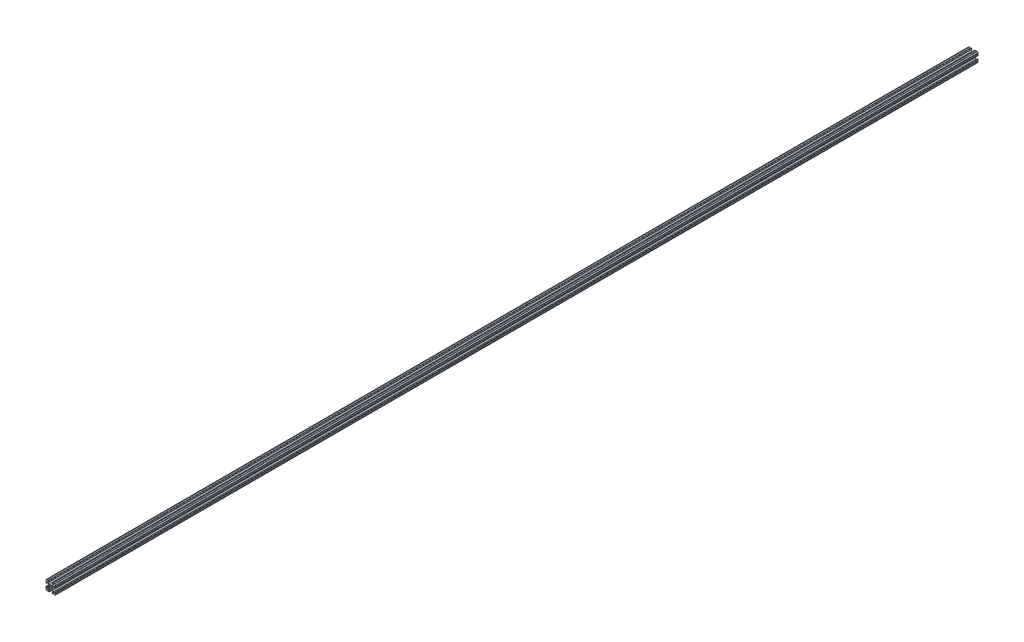
from build123d import *

# Parameters (mm, degrees)
SKETCH1_R           = 2.6035
BOSS_EXTRUDE1_DEPTH = 2438.4


with BuildPart() as part:
    # Sketch1 → Boss-Extrude1 (new body)
    with BuildSketch(Plane.XY):
        with BuildLine():
            Line((-12.7, -6.3330836), (-12.7, -9.5504))
            ThreePointArc((-12.7, -9.5504), (-12.192000006, -10.058323491), (-12.699846982, -10.566399977))
            ThreePointArc((-12.699846982, -10.566399977), (-12.082522516, -12.082522516), (-10.566399977, -12.699846982))
            ThreePointArc((-10.566399977, -12.699846982), (-10.058323491, -12.192000006), (-9.5504, -12.7))
            Line((-9.5504, -12.7), (-6.3330836, -12.7))
            ThreePointArc((-6.3330836, -12.7), (-5.8250836, -12.192), (-5.3170836, -12.7))
            Line((-5.3170836, -12.7), (-4.343399971, -12.7))
            ThreePointArc((-4.343399971, -12.7), (-3.238499971, -11.5951), (-4.343399971, -10.4902))
            Line((-4.343399971, -10.4902), (-6.474794456, -10.4902))
            ThreePointArc((-6.474794456, -10.4902), (-7.413456061, -9.863006367), (-7.193214945, -8.75577951))
            Line((-7.193214945, -8.75577951), (-3.863171405, -5.42573597))
            ThreePointArc((-3.863171405, -5.42573597), (-2.833127272, -4.737482484), (-1.618107374, -4.4958))
            Line((-1.618107374, -4.4958), (1.618107374, -4.4958))
            ThreePointArc((1.618107374, -4.4958), (2.833127272, -4.737482484), (3.863171405, -5.42573597))
            Line((3.863171405, -5.42573597), (7.193214945, -8.75577951))
            ThreePointArc((7.193214945, -8.75577951), (7.413456061, -9.863006367), (6.474794456, -10.4902))
            Line((6.474794456, -10.4902), (4.3434, -10.4902))
            ThreePointArc((4.3434, -10.4902), (3.2385, -11.5951), (4.3434, -12.7))
            Line((4.3434, -12.7), (5.3170836, -12.7))
            ThreePointArc((5.3170836, -12.7), (5.8250836, -12.192), (6.3330836, -12.7))
            Line((6.3330836, -12.7), (9.5504, -12.7))
            ThreePointArc((9.5504, -12.7), (10.058323491, -12.192000006), (10.566399977, -12.699846982))
            ThreePointArc((10.566399977, -12.699846982), (12.082522516, -12.082522516), (12.699846982, -10.566399977))
            ThreePointArc((12.699846982, -10.566399977), (12.192000006, -10.058323491), (12.7, -9.5504))
            Line((12.7, -9.5504), (12.7, -6.3330836))
            ThreePointArc((12.7, -6.3330836), (12.192, -5.8250836), (12.7, -5.3170836))
            Line((12.7, -5.3170836), (12.7, -4.343399971))
            ThreePointArc((12.7, -4.343399971), (11.5951, -3.238499971), (10.4902, -4.343399971))
            Line((10.4902, -4.343399971), (10.4902, -6.474794456))
            ThreePointArc((10.4902, -6.474794456), (9.863006367, -7.413456061), (8.75577951, -7.193214945))
            Line((8.75577951, -7.193214945), (5.42573597, -3.863171405))
            ThreePointArc((5.42573597, -3.863171405), (4.737482484, -2.833127272), (4.4958, -1.618107374))
            Line((4.4958, -1.618107374), (4.4958, 1.618107374))
            ThreePointArc((4.4958, 1.618107374), (4.737482484, 2.833127272), (5.42573597, 3.863171405))
            Line((5.42573597, 3.863171405), (8.75577951, 7.193214945))
            ThreePointArc((8.75577951, 7.193214945), (9.863006367, 7.413456061), (10.4902, 6.474794456))
            Line((10.4902, 6.474794456), (10.4902, 4.3434))
            ThreePointArc((10.4902, 4.3434), (11.5951, 3.2385), (12.7, 4.3434))
            Line((12.7, 4.3434), (12.7, 5.3170836))
            ThreePointArc((12.7, 5.3170836), (12.192, 5.8250836), (12.7, 6.3330836))
            Line((12.7, 6.3330836), (12.7, 9.5504))
            ThreePointArc((12.7, 9.5504), (12.192000006, 10.058323491), (12.699846982, 10.566399977))
            ThreePointArc((12.699846982, 10.566399977), (12.082522516, 12.082522516), (10.566399977, 12.699846982))
            ThreePointArc((10.566399977, 12.699846982), (10.058323491, 12.192000006), (9.5504, 12.7))
            Line((9.5504, 12.7), (6.3330836, 12.7))
            ThreePointArc((6.3330836, 12.7), (5.8250836, 12.192), (5.3170836, 12.7))
            Line((5.3170836, 12.7), (4.343399971, 12.7))
            ThreePointArc((4.343399971, 12.7), (3.238499971, 11.5951), (4.343399971, 10.4902))
            Line((4.343399971, 10.4902), (6.474794456, 10.4902))
            ThreePointArc((6.474794456, 10.4902), (7.413456061, 9.863006367), (7.193214945, 8.75577951))
            Line((7.193214945, 8.75577951), (3.863171405, 5.42573597))
            ThreePointArc((3.863171405, 5.42573597), (2.833127272, 4.737482484), (1.618107374, 4.4958))
            Line((1.618107374, 4.4958), (-1.618107374, 4.4958))
            ThreePointArc((-1.618107374, 4.4958), (-2.833127272, 4.737482484), (-3.863171405, 5.42573597))
            Line((-3.863171405, 5.42573597), (-7.193214945, 8.75577951))
            ThreePointArc((-7.193214945, 8.75577951), (-7.413456061, 9.863006367), (-6.474794456, 10.4902))
            Line((-6.474794456, 10.4902), (-4.3434, 10.4902))
            ThreePointArc((-4.3434, 10.4902), (-3.2385, 11.5951), (-4.3434, 12.7))
            Line((-4.3434, 12.7), (-5.3170836, 12.7))
            ThreePointArc((-5.3170836, 12.7), (-5.8250836, 12.192), (-6.3330836, 12.7))
            Line((-6.3330836, 12.7), (-9.5504, 12.7))
            ThreePointArc((-9.5504, 12.7), (-10.058323491, 12.192000006), (-10.566399977, 12.699846982))
            ThreePointArc((-10.566399977, 12.699846982), (-12.082522516, 12.082522516), (-12.699846982, 10.566399977))
            ThreePointArc((-12.699846982, 10.566399977), (-12.192000006, 10.058323491), (-12.7, 9.5504))
            Line((-12.7, 9.5504), (-12.7, 6.3330836))
            ThreePointArc((-12.7, 6.3330836), (-12.192, 5.8250836), (-12.7, 5.3170836))
            Line((-12.7, 5.3170836), (-12.7, 4.343399971))
            ThreePointArc((-12.7, 4.343399971), (-11.5951, 3.238499971), (-10.4902, 4.343399971))
            Line((-10.4902, 4.343399971), (-10.4902, 6.474794456))
            ThreePointArc((-10.4902, 6.474794456), (-9.863006367, 7.413456061), (-8.75577951, 7.193214945))
            Line((-8.75577951, 7.193214945), (-5.42573597, 3.863171405))
            ThreePointArc((-5.42573597, 3.863171405), (-4.737482484, 2.833127272), (-4.4958, 1.618107374))
            Line((-4.4958, 1.618107374), (-4.4958, -1.618107374))
            ThreePointArc((-4.4958, -1.618107374), (-4.737482484, -2.833127272), (-5.42573597, -3.863171405))
            Line((-5.42573597, -3.863171405), (-8.75577951, -7.193214945))
            ThreePointArc((-8.75577951, -7.193214945), (-9.863006367, -7.413456061), (-10.4902, -6.474794456))
            Line((-10.4902, -6.474794456), (-10.4902, -4.3434))
            ThreePointArc((-10.4902, -4.3434), (-11.5951, -3.2385), (-12.7, -4.3434))
            Line((-12.7, -4.3434), (-12.7, -5.3170836))
            ThreePointArc((-12.7, -5.3170836), (-12.192, -5.8250836), (-12.7, -6.3330836))
        make_face()
        Circle(SKETCH1_R, mode=Mode.SUBTRACT)
    extrude(amount=-BOSS_EXTRUDE1_DEPTH)


solid = part.part
